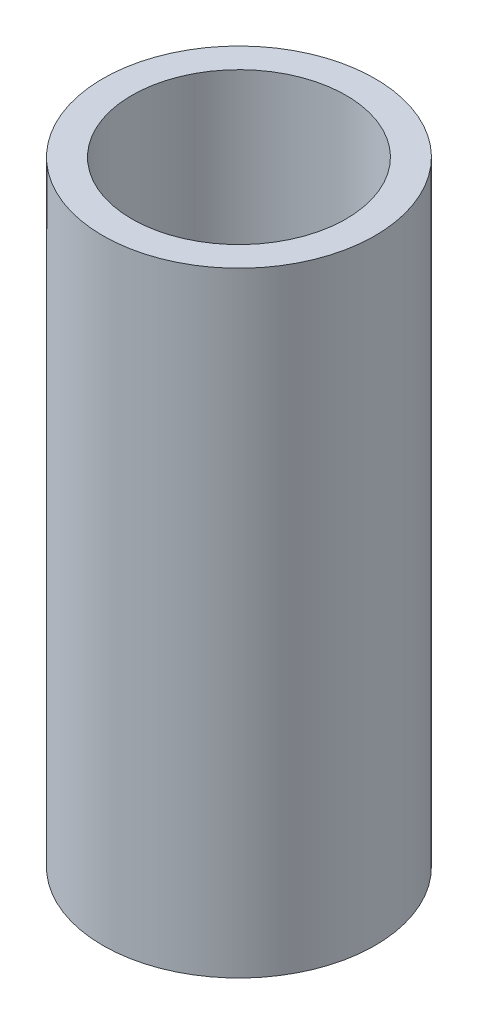
from build123d import *

# Parameters (mm, degrees)
SKETCH_1_R      = 15.5
SKETCH_1_R_2    = 12.2
EXTRUDE_1_DEPTH = 70


with BuildPart() as part:
    # Эскиз1 → Бобышка-Вытянуть1 (new body)
    with BuildSketch(Plane(origin=(0, 0, 0), x_dir=(1, 0, 0), z_dir=(0, 1, 0))):
        Circle(SKETCH_1_R)
        Circle(SKETCH_1_R_2, mode=Mode.SUBTRACT)
    extrude(amount=EXTRUDE_1_DEPTH)


solid = part.part
